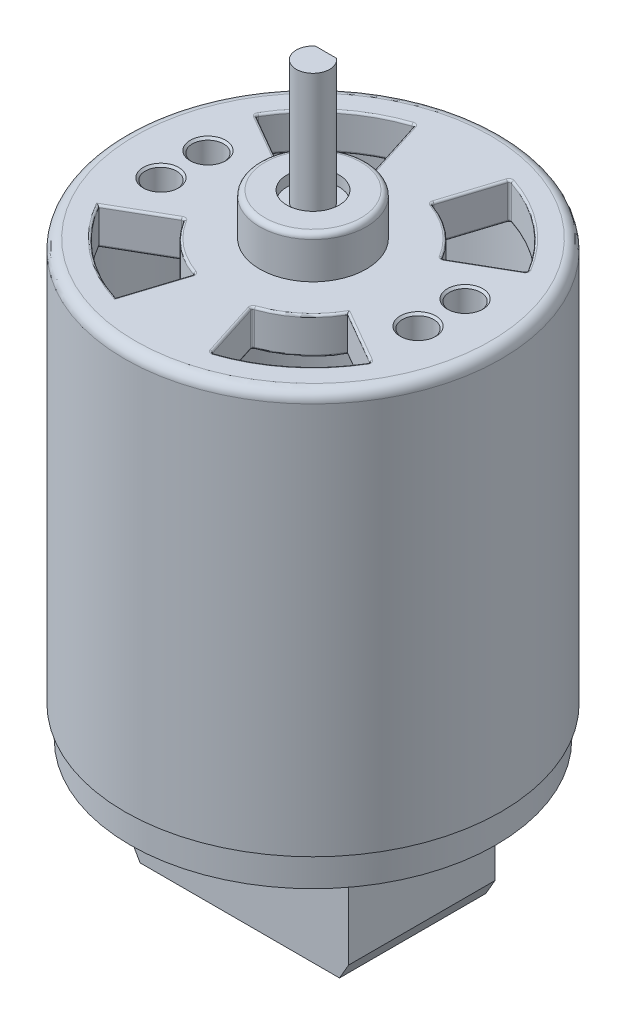
from build123d import *
from OCP.BRepFilletAPI import BRepFilletAPI_MakeChamfer

# Parameters (mm, degrees)
SKETCH1_R            = 18
EXTRUDE1_DEPTH       = 38.5
SKETCH2_R            = 5.1
EXTRUDE2_DEPTH       = 4
SKETCH3_R            = 1.6
EXTRUDE3_DEPTH       = 10.8
EXTRUDE4_DEPTH       = 10.8
SKETCH5_R            = 16
EXTRUDE5_DEPTH       = 35
SKETCH6_R            = 1.5
EXTRUDE6_DEPTH       = 35
EXTRUDE7_DEPTH       = 35
FILLET1_R            = 0.2
CHAMFER1_SIZE        = 0.2
FILLET2_R            = 0.5
SKETCH8_R            = 2.5
SKETCH8_R_2          = 1.6
EXTRUDE8_DEPTH       = 1
FILLET3_R            = 1
SKETCH9_R            = 17.5
EXTRUDE11_DEPTH      = 15
SKETCH10_OUTSIDE_W   = 55.038
SKETCH10_OUTSIDE_H   = 55.038
SKETCH10_OUTSIDE_W_2 = 52.783701282
SKETCH10_OUTSIDE_H_2 = 14
EXTRUDE12_DEPTH      = 12
SKETCH11_OUTSIDE_W   = 55.038
SKETCH11_OUTSIDE_H   = 55.038
SKETCH11_OUTSIDE_W_2 = 20.8
SKETCH11_OUTSIDE_H_2 = 14
EXTRUDE13_DEPTH      = 12
CHAMFER2_SIZE        = 2
CHAMFER2_SIZE2       = 1.154700538
SKETCH12_OUTSIDE_W   = 55.038
SKETCH12_OUTSIDE_H   = 55.038
SKETCH12_OUTSIDE_R   = 6
EXTRUDE15_DEPTH      = 0.5
SKETCH13_R           = 2.5
SKETCH13_R_2         = 1.6
EXTRUDE16_DEPTH      = 1


with BuildPart() as part:
    # Sketch1 → Extrude1 (new body)
    with BuildSketch(Plane(origin=(0, 0, 0), x_dir=(1, 0, 0), z_dir=(0, 1, 0))):
        with Locations(Location((0, 0, 0), (0, 0, 270))):
            Circle(SKETCH1_R)
    extrude(amount=EXTRUDE1_DEPTH)

    # Sketch2 → Extrude2 (add)
    with BuildSketch(Plane(origin=(0, 38.5, 0), x_dir=(1, 0, 0), z_dir=(0, 1, 0))):
        with Locations(Location((0, 0, 0), (0, 0, 270))):
            Circle(SKETCH2_R)
    extrude(amount=EXTRUDE2_DEPTH)

    # Sketch3 → Extrude3 (add)
    with BuildSketch(Plane(origin=(0, 42.5, 0), x_dir=(1, 0, 0), z_dir=(0, 1, 0))):
        with Locations(Location((0, 0, 0), (0, 0, 90))):
            Circle(SKETCH3_R)
    extrude(amount=EXTRUDE3_DEPTH)

    # Sketch4 → Extrude4 (cut)
    with BuildSketch(Plane(origin=(0, 53.3, 0), x_dir=(1, 0, 0), z_dir=(0, 1, 0))):
        with BuildLine():
            Line((1.011137973, 1.24), (-1.011137973, 1.24))
            ThreePointArc((-1.011137973, 1.24), (0, 1.6), (1.011137973, 1.24))
        make_face()
    extrude(amount=-EXTRUDE4_DEPTH, mode=Mode.SUBTRACT)

    # Sketch5 → Extrude5 (cut)
    with BuildSketch(Plane.XZ):
        with Locations(Location((0, 0, 0), (0, 0, 270))):
            Circle(SKETCH5_R)
    extrude(amount=-EXTRUDE5_DEPTH, mode=Mode.SUBTRACT)

    # Sketch6 → Extrude6 (cut)
    with BuildSketch(Plane(origin=(0, 38.5, 0), x_dir=(-1, 0, 0), z_dir=(0, 1, 0))):
        with Locations(Location((12.295832627, -2.25, 0), (0, 0, 90))):
            Circle(SKETCH6_R)
        with Locations(Location((12.295832627, 2.25, 0), (0, 0, 90))):
            Circle(SKETCH6_R)
        with Locations(Location((-12.295832627, -2.25, 0), (0, 0, 90))):
            Circle(SKETCH6_R)
        with Locations(Location((-12.295832627, 2.25, 0), (0, 0, 90))):
            Circle(SKETCH6_R)
    extrude(amount=-EXTRUDE6_DEPTH, mode=Mode.SUBTRACT)

    # Sketch7 → Extrude7 (cut)
    with BuildSketch(Plane(origin=(0, 38.5, 0), x_dir=(1, 0, 0), z_dir=(0, 1, 0))):
        with BuildLine():
            Line((-7.794228634, 4.5), (-12.990381057, 7.5))
            ThreePointArc((-12.990381057, 7.5), (-9.41071131, 11.680689733), (-4.56405859, 14.288784735))
            Line((-4.56405859, 14.288784735), (-2.738435154, 8.573270841))
            ThreePointArc((-2.738435154, 8.573270841), (-5.646426786, 7.00841384), (-7.794228634, 4.5))
        make_face()
        with BuildLine():
            Line((2.738435154, 8.573270841), (4.56405859, 14.288784735))
            ThreePointArc((4.56405859, 14.288784735), (9.41071131, 11.680689733), (12.990381057, 7.5))
            Line((12.990381057, 7.5), (7.794228634, 4.5))
            ThreePointArc((7.794228634, 4.5), (5.646426786, 7.00841384), (2.738435154, 8.573270841))
        make_face()
        with BuildLine():
            Line((-2.738435154, -8.573270841), (-4.56405859, -14.288784735))
            ThreePointArc((-4.56405859, -14.288784735), (-9.41071131, -11.680689733), (-12.990381057, -7.5))
            Line((-12.990381057, -7.5), (-7.794228634, -4.5))
            ThreePointArc((-7.794228634, -4.5), (-5.646426786, -7.00841384), (-2.738435154, -8.573270841))
        make_face()
        with BuildLine():
            Line((2.738435154, -8.573270841), (4.56405859, -14.288784735))
            ThreePointArc((4.56405859, -14.288784735), (9.41071131, -11.680689733), (12.990381057, -7.5))
            Line((12.990381057, -7.5), (7.794228634, -4.5))
            ThreePointArc((7.794228634, -4.5), (5.646426786, -7.00841384), (2.738435154, -8.573270841))
        make_face()
    extrude(amount=-EXTRUDE7_DEPTH, mode=Mode.SUBTRACT)

    # Fillet1
    fillet1_edges = [part.edges().sort_by_distance(p)[0] for p in [
        (12.990381057, 36.75, 7.5),
        (4.56405859, 36.75, 14.288784735),
        (2.738435154, 36.75, 8.573270841),
        (9.41071131, 38.5, 11.680689733),
        (10.392304845, 38.5, 6),
        (5.646426786, 38.5, 7.00841384),
        (3.651246872, 38.5, 11.431027788),
        (3.651246872, 35, -11.431027788),
        (5.646426786, 35, -7.00841384),
        (10.392304845, 35, -6),
        (9.41071131, 35, -11.680689733),
        (4.56405859, 36.75, -14.288784735),
        (12.990381057, 36.75, -7.5),
        (7.794228634, 36.75, -4.5),
        (2.738435154, 36.75, -8.573270841),
        (9.41071131, 38.5, -11.680689733),
        (3.651246872, 38.5, -11.431027788),
        (5.646426786, 38.5, -7.00841384),
        (10.392304845, 38.5, -6),
        (-10.392304845, 35, 6),
        (-9.41071131, 35, 11.680689733),
        (-3.651246872, 35, 11.431027788),
        (-5.646426786, 35, 7.00841384),
        (-7.794228634, 36.75, 4.5),
        (-2.738435154, 36.75, 8.573270841),
        (-5.646426786, 38.5, 7.00841384),
        (-10.392304845, 38.5, 6),
        (-9.41071131, 38.5, 11.680689733),
        (-3.651246872, 38.5, 11.431027788),
        (-10.392304845, 35, -6),
        (-5.646426786, 35, -7.00841384),
        (-3.651246872, 35, -11.431027788),
        (-9.41071131, 35, -11.680689733),
        (-12.990381057, 36.75, -7.5),
        (-4.56405859, 36.75, -14.288784735),
        (-2.738435154, 36.75, -8.573270841),
        (-7.794228634, 36.75, -4.5),
        (-9.41071131, 38.5, -11.680689733),
        (-10.392304845, 38.5, -6),
        (-5.646426786, 38.5, -7.00841384),
        (-3.651246872, 38.5, -11.431027788),
        (10.392304845, 35, 6),
        (5.646426786, 35, 7.00841384),
        (3.651246872, 35, 11.431027788),
        (9.41071131, 35, 11.680689733),
    ]]
    fillet(fillet1_edges, radius=FILLET1_R)

    # Chamfer1
    chamfer1_edges = [part.edges().sort_by_distance(p)[0] for p in [
        (-12.295832627, 38.5, -3.75),
        (-12.295832627, 38.5, 0.75),
        (12.295832627, 38.5, -3.75),
        (12.295832627, 38.5, 0.75),
    ]]
    chamfer(chamfer1_edges, length=CHAMFER1_SIZE)

    # Fillet2
    fillet2_edges = [part.edges().sort_by_distance(p)[0] for p in [
        (0, 42.5, -5.1),
    ]]
    fillet(fillet2_edges, radius=FILLET2_R)

    # Sketch8 → Extrude8 (cut)
    with BuildSketch(Plane(origin=(0, 42.5, 0), x_dir=(1, 0, 0), z_dir=(0, 1, 0))):
        with Locations(Location((0, 0, 0), (0, 0, 270))):
            Circle(SKETCH8_R)
        with Locations(Location((0, 0, 0), (0, 0, 129.194967426))):
            Circle(SKETCH8_R_2, mode=Mode.SUBTRACT)
    extrude(amount=-EXTRUDE8_DEPTH, mode=Mode.SUBTRACT)

    # Fillet3
    fillet3_edges = [part.edges().sort_by_distance(p)[0] for p in [
        (0, 38.5, -18),
    ]]
    fillet(fillet3_edges, radius=FILLET3_R)

    # Sketch9 → Extrude11 (add)
    with BuildSketch(Plane.XZ):
        with Locations(Location((0, 0, 0), (0, 0, 90))):
            Circle(SKETCH9_R)
    extrude(amount=EXTRUDE11_DEPTH)

    # Sketch10 outside → Extrude12 (cut)
    with BuildSketch(Plane.XZ.offset(15)):
        Rectangle(SKETCH10_OUTSIDE_W, SKETCH10_OUTSIDE_H)
        Rectangle(SKETCH10_OUTSIDE_W_2, SKETCH10_OUTSIDE_H_2, mode=Mode.SUBTRACT)
    extrude(amount=-EXTRUDE12_DEPTH, mode=Mode.SUBTRACT)

    # Sketch11 outside → Extrude13 (cut)
    with BuildSketch(Plane.XZ.offset(15)):
        Rectangle(SKETCH11_OUTSIDE_W, SKETCH11_OUTSIDE_H)
        Rectangle(SKETCH11_OUTSIDE_W_2, SKETCH11_OUTSIDE_H_2, mode=Mode.SUBTRACT)
    extrude(amount=-EXTRUDE13_DEPTH, mode=Mode.SUBTRACT)

    # Chamfer2: one chamfer whose edges measure the first distance from different faces: ONE call of the kernel's chamfer builder (chamfer() names one face for all edges)
    chamfer2_edges_1 = [part.edges().sort_by_distance(p)[0] for p in [
        (10.4, -15, 0),
    ]]
    chamfer2_side_1 = [part.faces().sort_by_distance(p)[0] for p in [
        (10.4, -9, 0),
    ]]
    chamfer2_edges_2 = [part.edges().sort_by_distance(p)[0] for p in [
        (-10.4, -15, 0),
    ]]
    chamfer2_side_2 = [part.faces().sort_by_distance(p)[0] for p in [
        (-10.4, -9, 0),
    ]]
    chamfer2 = BRepFilletAPI_MakeChamfer(part.part.solid().wrapped)
    for e in chamfer2_edges_1:
        chamfer2.Add(CHAMFER2_SIZE, CHAMFER2_SIZE2, e.wrapped, chamfer2_side_1[0].wrapped)  # the first distance lies on this face
    for e in chamfer2_edges_2:
        chamfer2.Add(CHAMFER2_SIZE, CHAMFER2_SIZE2, e.wrapped, chamfer2_side_2[0].wrapped)  # the first distance lies on this face
    add(Compound.cast(chamfer2.Shape()), mode=Mode.REPLACE)

    # Sketch12 outside → Extrude15 (cut)
    with BuildSketch(Plane.XZ.offset(15)):
        Rectangle(SKETCH12_OUTSIDE_W, SKETCH12_OUTSIDE_H)
        with Locations(Location((0, 0, 0), (0, 0, 270))):
            Circle(SKETCH12_OUTSIDE_R, mode=Mode.SUBTRACT)
    extrude(amount=-EXTRUDE15_DEPTH, mode=Mode.SUBTRACT)

    # Sketch13 → Extrude16 (cut)
    with BuildSketch(Plane.XZ.offset(15)):
        with Locations(Location((0, 0, 0), (0, 0, 90))):
            Circle(SKETCH13_R)
        with Locations(Location((0, 0, 0), (0, 0, 230.805032574))):
            Circle(SKETCH13_R_2, mode=Mode.SUBTRACT)
    extrude(amount=-EXTRUDE16_DEPTH, mode=Mode.SUBTRACT)


solid = part.part
